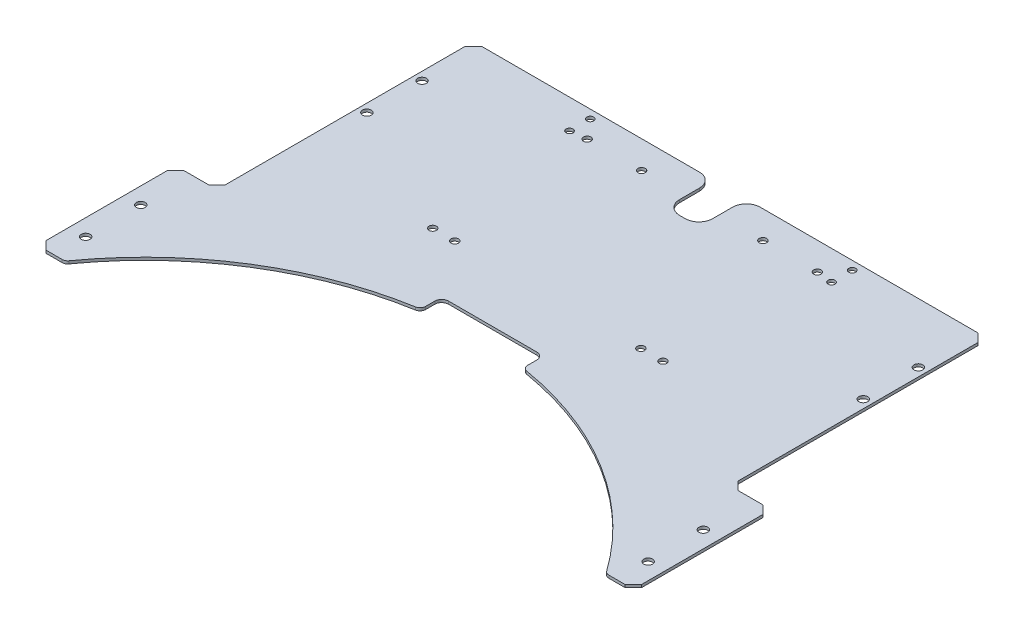
from build123d import *

# Parameters (mm, degrees)
SKETCH_1_W          = 186
SKETCH_1_H          = 110
EXTRUDE_1_DEPTH     = 1
SKETCH_2_R          = 1.6
CUT_EXTRUDE_1_DEPTH = 2
EXTRUDE_2_DEPTH     = 1
SKETCH_6_R          = 120
CUT_EXTRUDE_2_DEPTH = 2
SKETCH_8_W          = 186
SKETCH_8_H          = 2
EXTRUDE_3_DEPTH     = 1
SKETCH_7_R          = 1.25
SKETCH_7_R_2        = 1.6
CUT_EXTRUDE_3_DEPTH = 2
CHAMFER_1_SIZE      = 3
FILLET_1_R          = 2
CUT_EXTRUDE_4_DEPTH = 2
SKETCH_10_R         = 1.35
CUT_EXTRUDE_5_DEPTH = 2
SKETCH_11_W         = 12
SKETCH_11_H         = 17.2
CUT_EXTRUDE_6_DEPTH = 2
FILLET_2_R          = 5
FILLET_3_R          = 2


with BuildPart() as part:
    # 草图1 → 凸台-拉伸1 (new body)
    with BuildSketch(Plane(origin=(0, 0, 0), x_dir=(1, 0, 0), z_dir=(0, 1, 0))):
        Rectangle(SKETCH_1_W, SKETCH_1_H)
    extrude(amount=EXTRUDE_1_DEPTH)

    # 草图2 → 切除-拉伸1 (cut, through all)
    with BuildSketch(Plane(origin=(0, 1, 0), x_dir=(1, 0, 0), z_dir=(0, 1, 0))):
        with Locations((90, 15.38)):
            Circle(SKETCH_2_R)
        with Locations((90, 35.38)):
            Circle(SKETCH_2_R)
        with Locations((-90, 35.38)):
            Circle(SKETCH_2_R)
        with Locations((-90, 15.38)):
            Circle(SKETCH_2_R)
    extrude(amount=-CUT_EXTRUDE_1_DEPTH, mode=Mode.SUBTRACT)

    # 草图5 → 凸台-拉伸2 (add)
    with BuildSketch(Plane(origin=(0, 1, 0), x_dir=(1, 0, 0), z_dir=(0, 1, 0))):
        Polygon((-108, -86), (108, -86), (108, -36), (93, -36), (93, -55), (-93, -55), (-93, -36), (-108, -36), align=None)
    extrude(amount=-EXTRUDE_2_DEPTH)

    # 草图6 → 切除-拉伸2 (cut, through all)
    with BuildSketch(Plane(origin=(0, 1, 0), x_dir=(1, 0, 0), z_dir=(0, 1, 0))):
        with Locations((0, -155.12)):
            Circle(SKETCH_6_R)
    extrude(amount=-CUT_EXTRUDE_2_DEPTH, mode=Mode.SUBTRACT)

    # 草图8 → 凸台-拉伸3 (add)
    with BuildSketch(Plane(origin=(0, 1, 0), x_dir=(1, 0, 0), z_dir=(0, 1, 0))):
        with Locations((0, 56)):
            Rectangle(SKETCH_8_W, SKETCH_8_H)
    extrude(amount=-EXTRUDE_3_DEPTH)

    # 草图7 → 切除-拉伸3 (cut, through all)
    with BuildSketch(Plane(origin=(0, 1, 0), x_dir=(1, 0, 0), z_dir=(0, 1, 0))):
        with Locations((47.5, 46.38)):
            Circle(SKETCH_7_R)
        with Locations((47.5, 53.88)):
            Circle(SKETCH_7_R)
        with Locations((102, -74.62)):
            Circle(SKETCH_7_R_2)
        with Locations((102, -54.62)):
            Circle(SKETCH_7_R_2)
        with Locations((-102, -54.62)):
            Circle(SKETCH_7_R_2)
        with Locations((-102, -74.62)):
            Circle(SKETCH_7_R_2)
        with Locations((-47.5, 53.88)):
            Circle(SKETCH_7_R)
        with Locations((-47.5, 46.38)):
            Circle(SKETCH_7_R)
    extrude(amount=-CUT_EXTRUDE_3_DEPTH, mode=Mode.SUBTRACT)

    # 倒角1
    chamfer_1_edges = [part.edges().sort_by_distance(p)[0] for p in [
        (-93, 0.5, 36),
        (93, 0.5, 36),
        (108, 0.5, 36),
        (108, 0.5, 86),
        (-108, 0.5, 86),
        (-108, 0.5, 36),
        (93, 0.5, -57),
        (-93, 0.5, -57),
    ]]
    chamfer(chamfer_1_edges, length=CHAMFER_1_SIZE)

    # 圆角1
    fillet_1_edges = [part.edges().sort_by_distance(p)[0] for p in [
        (-98.093963117, 0.5, 86),
        (98.093963117, 0.5, 86),
    ]]
    fillet(fillet_1_edges, radius=FILLET_1_R)

    # 草图9 → 切除-拉伸4 (cut, through all)
    with BuildSketch(Plane(origin=(0, 1, 0), x_dir=(1, 0, 0), z_dir=(0, 1, 0))):
        with BuildLine():
            Line((16, -29), (-16, -29))
            ThreePointArc((-16, -29), (-17.767766953, -29.732233047), (-18.5, -31.5))
            Line((-18.5, -31.5), (-18.5, -36.554617194))
            ThreePointArc((-18.5, -36.554617194), (0, -35.12), (18.5, -36.554617194))
            Line((18.5, -36.554617194), (18.5, -31.5))
            ThreePointArc((18.5, -31.5), (17.767766953, -29.732233047), (16, -29))
        make_face()
    extrude(amount=-CUT_EXTRUDE_4_DEPTH, mode=Mode.SUBTRACT)

    # 草图10 → 切除-拉伸5 (cut, through all)
    with BuildSketch(Plane(origin=(0, 1, 0), x_dir=(1, 0, 0), z_dir=(0, 1, 0))):
        with Locations((-33.75, -9)):
            Circle(SKETCH_10_R)
        with Locations((-22, 47)):
            Circle(SKETCH_10_R)
        with Locations((22, 47)):
            Circle(SKETCH_10_R)
        with Locations((33.75, -9)):
            Circle(SKETCH_10_R)
        with Locations((41.75, -9)):
            Circle(SKETCH_10_R)
        with Locations((-41.75, -9)):
            Circle(SKETCH_10_R)
        with Locations((41.75, 47)):
            Circle(SKETCH_10_R)
        with Locations((-41.75, 47)):
            Circle(SKETCH_10_R)
    extrude(amount=-CUT_EXTRUDE_5_DEPTH, mode=Mode.SUBTRACT)

    # 草图11 → 切除-拉伸6 (cut, through all)
    with BuildSketch(Plane(origin=(0, 1, 0), x_dir=(1, 0, 0), z_dir=(0, 1, 0))):
        with Locations((0, 48.4)):
            Rectangle(SKETCH_11_W, SKETCH_11_H)
    extrude(amount=-CUT_EXTRUDE_6_DEPTH, mode=Mode.SUBTRACT)

    # 圆角2
    fillet_2_edges = [part.edges().sort_by_distance(p)[0] for p in [
        (6, 0.5, -39.8),
        (-6, 0.5, -39.8),
        (-6, 0.5, -57),
        (6, 0.5, -57),
    ]]
    fillet(fillet_2_edges, radius=FILLET_2_R)

    # 圆角3
    fillet_3_edges = [part.edges().sort_by_distance(p)[0] for p in [
        (18.5, 0.5, 36.554617194),
        (-18.5, 0.5, 36.554617194),
    ]]
    fillet(fillet_3_edges, radius=FILLET_3_R)


solid = part.part
